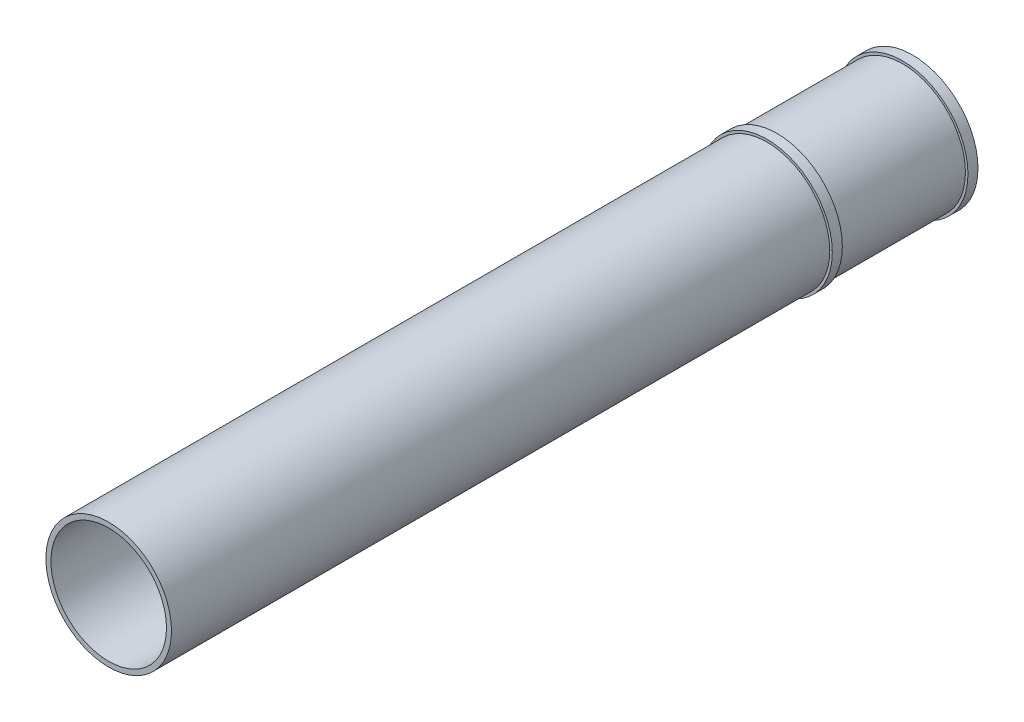
from build123d import *

# Parameters (mm, degrees)
SKETCH2_R           = 25
SKETCH2_R_2         = 23
BOSS_EXTRUDE1_DEPTH = 320
BOSS_EXTRUDE2_START = 54
SKETCH2_3_R         = 26
SKETCH2_3_R_2       = 25
BOSS_EXTRUDE2_DEPTH = 4
SKETCH2_4_R         = 26
SKETCH2_4_R_2       = 25
BOSS_EXTRUDE3_DEPTH = 4


with BuildPart() as part:
    # Sketch2 → Boss-Extrude1 (new body)
    with BuildSketch(Plane.XY):
        Circle(SKETCH2_R)
        Circle(SKETCH2_R_2, mode=Mode.SUBTRACT)
    extrude(amount=BOSS_EXTRUDE1_DEPTH)

    # Sketch2_3 → Boss-Extrude2 (add)
    with BuildSketch(Plane.XY.offset(BOSS_EXTRUDE2_START)):
        Circle(SKETCH2_3_R)
        Circle(SKETCH2_3_R_2, mode=Mode.SUBTRACT)
    extrude(amount=BOSS_EXTRUDE2_DEPTH)

    # Sketch2_4 → Boss-Extrude3 (add)
    with BuildSketch(Plane.XY):
        Circle(SKETCH2_4_R)
        Circle(SKETCH2_4_R_2, mode=Mode.SUBTRACT)
    extrude(amount=BOSS_EXTRUDE3_DEPTH)


solid = part.part
